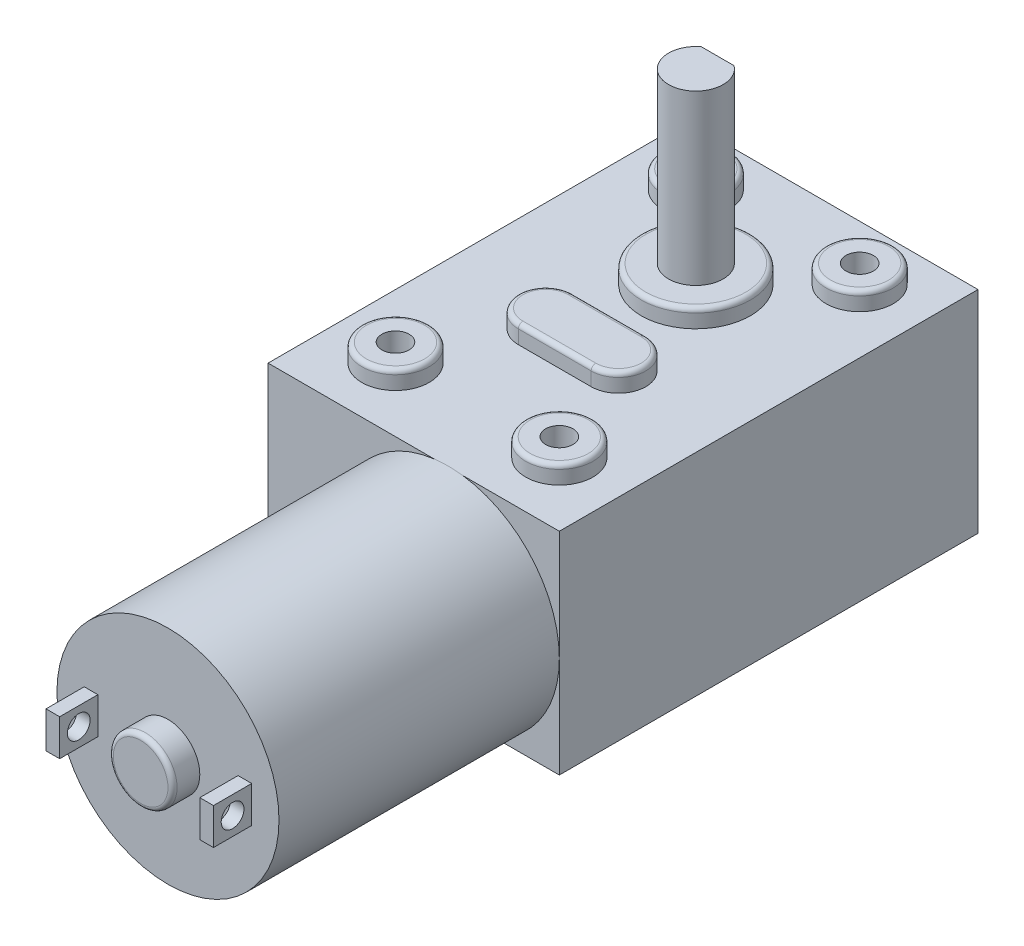
from build123d import *

# Parameters (mm, degrees)
ESBO_O4_R                      = 12.2
RESSALTO_EXTRUS_O3_DEPTH       = 15.4
ESBO_O6_W                      = 32
ESBO_O6_H                      = 46
RESSALTO_EXTRUS_O4_DEPTH       = 12.1
RESSALTO_EXTRUS_O4_DEPTH_BACK  = 11.1
ESBO_O7_R                      = 3.7
ESBO_O7_R_2                    = 6
RESSALTO_EXTRUS_O5_DEPTH       = 2
ESBO_O8_R                      = 3
RESSALTO_EXTRUS_O6_DEPTH       = 18.5
ESBO_O9_W                      = 6
ESBO_O9_H                      = 0.6
CORTE_EXTRUS_O1_DEPTH          = 12
ESBO_O10_R                     = 1.5
CORTE_EXTRUS_O2_EST_DEPTH      = 10
ESBO_O12_W                     = 1.5
ESBO_O12_H                     = 4
RESSALTO_EXTRUS_O8_EST_DEPTH   = 4.2
ESBO_O13_R                     = 1.25
CORTE_EXTRUS_O3_EST_DEPTH      = 13.2
CORTE_EXTRUS_O3_EST_DEPTH_BACK = 20.8
ESBO_O11_R                     = 3.5
RESSALTO_EXTRUS_O9_EST_DEPTH   = 3
FILETE2_R                      = 0.5


with BuildPart() as part:
    # Esboço4 → Ressalto-extrusão3 (new body, symmetric)
    with BuildSketch(Plane.XY):
        Circle(ESBO_O4_R)
    extrude(amount=RESSALTO_EXTRUS_O3_DEPTH, both=True)

    # Esboço6 → Ressalto-extrusão4 (add, two sides)
    with BuildSketch(Plane(origin=(0, 0, 0), x_dir=(1, 0, 0), z_dir=(0, 1, 0))) as ressalto_extrus_o4_sk:
        with Locations((-3.8, 38.4)):
            Rectangle(ESBO_O6_W, ESBO_O6_H)
    extrude(amount=RESSALTO_EXTRUS_O4_DEPTH)
    extrude(ressalto_extrus_o4_sk.sketch, amount=-RESSALTO_EXTRUS_O4_DEPTH_BACK)

    # Esboço7 → Ressalto-extrusão5 (add)
    with BuildSketch(Plane(origin=(0, 12.1, 0), x_dir=(1, 0, 0), z_dir=(0, 1, 0))):
        with Locations((-12.8, 55.4)):
            Circle(ESBO_O7_R)
        with Locations((5.2, 55.4)):
            Circle(ESBO_O7_R)
        with Locations((-12.8, 22.4)):
            Circle(ESBO_O7_R)
        with Locations((5.2, 22.4)):
            Circle(ESBO_O7_R)
        with Locations((-3.8, 46.4)):
            Circle(ESBO_O7_R_2)
        with BuildLine():
            Line((-7.8, 36.9), (0.2, 36.9))
            ThreePointArc((0.2, 36.9), (3.2, 33.9), (0.2, 30.9))
            Line((0.2, 30.9), (-7.8, 30.9))
            ThreePointArc((-7.8, 30.9), (-10.8, 33.9), (-7.8, 36.9))
        make_face()
    extrude(amount=RESSALTO_EXTRUS_O5_DEPTH)

    # Esboço8 → Ressalto-extrusão6 (add)
    with BuildSketch(Plane(origin=(0, 14.1, 0), x_dir=(1, 0, 0), z_dir=(0, 1, 0))):
        with Locations((-3.8, 46.4)):
            Circle(ESBO_O8_R)
    extrude(amount=RESSALTO_EXTRUS_O6_DEPTH)

    # Esboço9 → Corte-extrusão1 (cut)
    with BuildSketch(Plane(origin=(0, 32.6, 0), x_dir=(1, 0, 0), z_dir=(0, 1, 0))):
        with Locations((-3.8, 49.1)):
            Rectangle(ESBO_O9_W, ESBO_O9_H)
    extrude(amount=-CORTE_EXTRUS_O1_DEPTH, mode=Mode.SUBTRACT)

    # Esboço10 → Corte-extrusão2 - Est. (cut)
    with BuildSketch(Plane(origin=(0, 14.1, 0), x_dir=(1, 0, 0), z_dir=(0, 1, 0))):
        with Locations((-12.8, 55.4)):
            Circle(ESBO_O10_R)
        with Locations((5.2, 55.4)):
            Circle(ESBO_O10_R)
        with Locations((-12.8, 22.4)):
            Circle(ESBO_O10_R)
        with Locations((5.2, 22.4)):
            Circle(ESBO_O10_R)
    extrude(amount=-CORTE_EXTRUS_O2_EST_DEPTH, mode=Mode.SUBTRACT)

    # Esboço12 → Ressalto-extrusão8 - Est. (add)
    with BuildSketch(Plane.XY.offset(15.4)):
        with Locations((-8.45, 0)):
            Rectangle(ESBO_O12_W, ESBO_O12_H)
        with Locations((8.45, 0)):
            Rectangle(ESBO_O12_W, ESBO_O12_H)
    extrude(amount=RESSALTO_EXTRUS_O8_EST_DEPTH)

    # Esboço13 → Corte-extrusão3 - Est. (cut, two sides)
    with BuildSketch(Plane(origin=(0, 0, 0), x_dir=(0, 0, -1), z_dir=(1, 0, 0))) as corte_extrus_o3_est_sk:
        with Locations((-17.5, 0)):
            Circle(ESBO_O13_R)
    extrude(amount=CORTE_EXTRUS_O3_EST_DEPTH, mode=Mode.SUBTRACT)
    extrude(corte_extrus_o3_est_sk.sketch, amount=-CORTE_EXTRUS_O3_EST_DEPTH_BACK, mode=Mode.SUBTRACT)

    # Esboço11 → Ressalto-extrusão9 - Est. (add)
    with BuildSketch(Plane.XY.offset(15.4)):
        Circle(ESBO_O11_R)
    extrude(amount=RESSALTO_EXTRUS_O9_EST_DEPTH)

    # Filete2
    filete2_edges = [part.edges().sort_by_distance(p)[0] for p in [
        (-3.5, 0, 18.4),
        (-16.5, 14.1, -55.4),
        (1.5, 14.1, -55.4),
        (-16.5, 14.1, -22.4),
        (1.5, 14.1, -22.4),
        (-9.8, 14.1, -46.4),
        (-10.8, 14.1, -33.9),
        (-3.8, 14.1, -30.9),
        (3.2, 14.1, -33.9),
        (-3.8, 14.1, -36.9),
    ]]
    fillet(filete2_edges, radius=FILETE2_R)


solid = part.part
